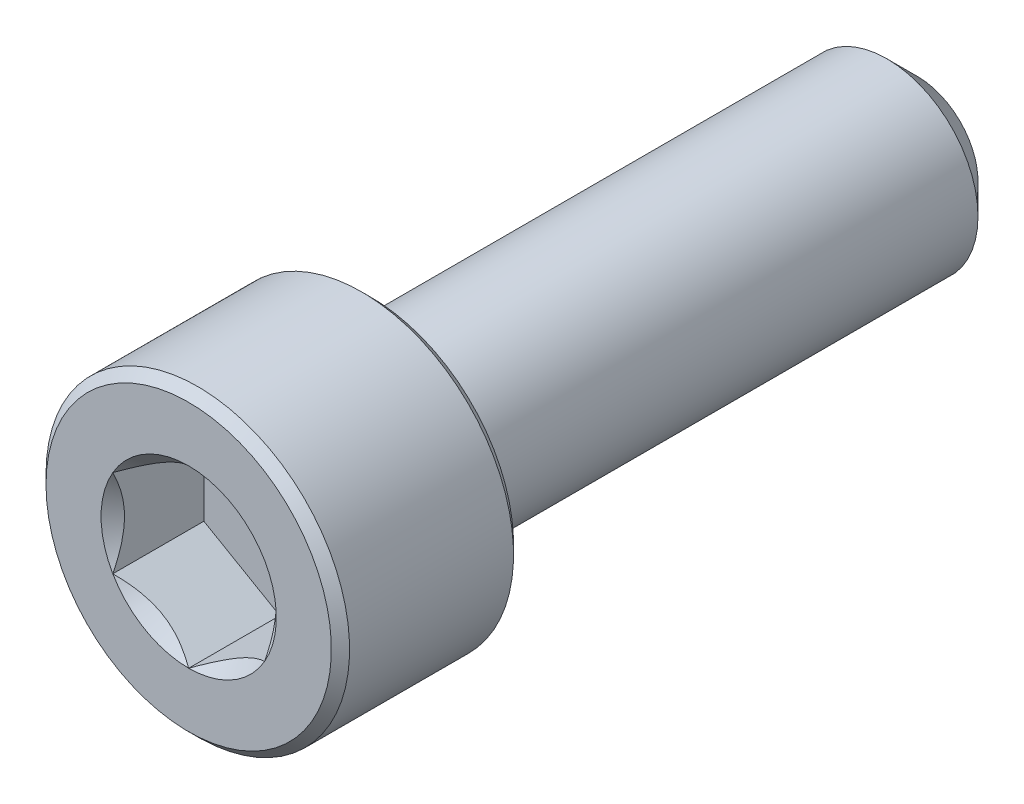
from build123d import *

# Parameters (mm, degrees)
CUT_EXTRUDE1_START = -3
CUT_EXTRUDE1_DEPTH = 3
SKETCH4_R          = 2.886751346
CUT_EXTRUDE2_DEPTH = 0.5
CUT_EXTRUDE2_TAPER = 45


with BuildPart() as part:
    # Sketch2 → Revolve1 (revolve)
    with BuildSketch(Plane(origin=(0, 0, 0), x_dir=(0, 0, -1), z_dir=(1, 0, 0))):
        Polygon((-11.7, 5), (-6.3, 5), (-6, 4.7), (-6, 3), (11, 3), (12, 2), (12, 0), (-12, 0), (-12, 4.7), align=None)
    revolve(axis=Axis((0, 0, -12), (0, 0, 1)))

    # Sketch3 → Cut-Extrude1 (cut)
    with BuildSketch(Plane.XY.offset(12).offset(CUT_EXTRUDE1_START)):
        Polygon((0, 2.886751346), (-2.5, 1.443375673), (-2.5, -1.443375673), (0, -2.886751346), (2.5, -1.443375673), (2.5, 1.443375673), align=None)
    extrude(amount=CUT_EXTRUDE1_DEPTH, mode=Mode.SUBTRACT)

    # Sketch4 → Cut-Extrude2 (cut)
    with BuildSketch(Plane.XY.offset(12)):
        Circle(SKETCH4_R)
    extrude(amount=-CUT_EXTRUDE2_DEPTH, taper=CUT_EXTRUDE2_TAPER, mode=Mode.SUBTRACT)


solid = part.part
